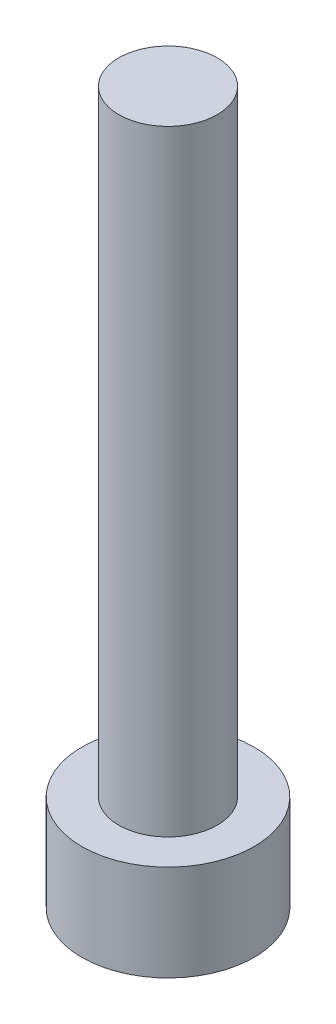
from build123d import *

# Parameters (mm, degrees)
SKETCH_1_R          = 3.5
EXTRUDE_1_DEPTH     = 3.9
SKETCH_2_R          = 2
EXTRUDE_2_DEPTH     = 25
CUT_EXTRUDE_1_DEPTH = 2.4


with BuildPart() as part:
    # 草图1 → 凸台-拉伸1 (new body)
    with BuildSketch(Plane(origin=(0, 0, 0), x_dir=(1, 0, 0), z_dir=(0, 1, 0))):
        Circle(SKETCH_1_R)
    extrude(amount=EXTRUDE_1_DEPTH)

    # 草图2 → 凸台-拉伸2 (add)
    with BuildSketch(Plane(origin=(0, 3.9, 0), x_dir=(1, 0, 0), z_dir=(0, 1, 0))):
        Circle(SKETCH_2_R)
    extrude(amount=EXTRUDE_2_DEPTH)

    # 草图3 → 切除-拉伸1 (cut)
    with BuildSketch(Plane.XZ):
        Polygon((1.725, 0), (0.8625, 1.493893822), (-0.8625, 1.493893822), (-1.725, 0), (-0.8625, -1.493893822), (0.8625, -1.493893822), align=None)
    extrude(amount=-CUT_EXTRUDE_1_DEPTH, mode=Mode.SUBTRACT)


solid = part.part
